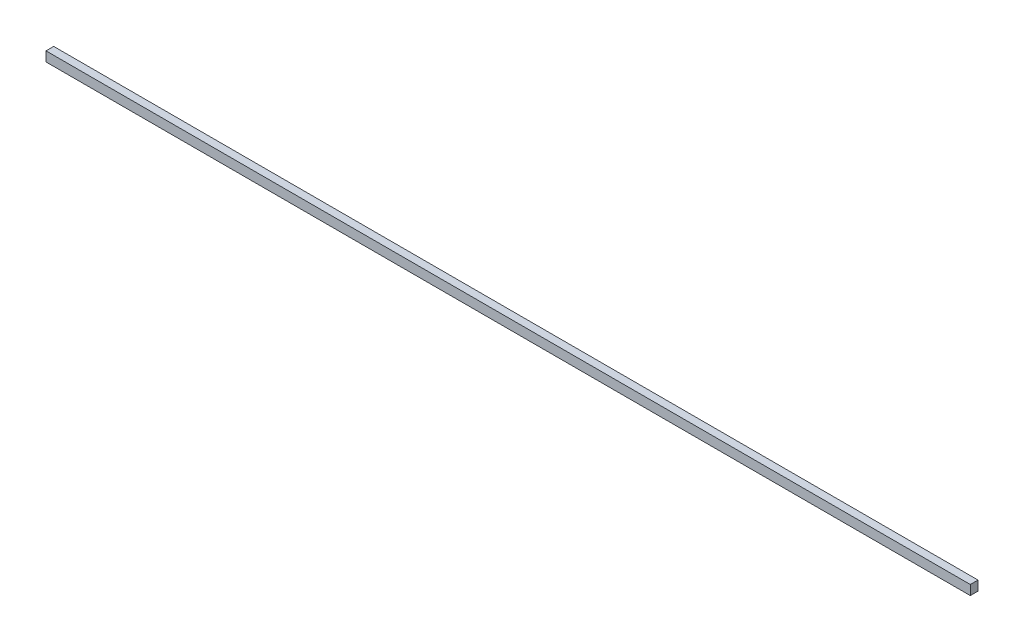
from build123d import *

# Parameters (mm, degrees)
SKETCH1_W           = 609.6
SKETCH1_H           = 6.35
BOSS_EXTRUDE1_DEPTH = 2.54


with BuildPart() as part:
    # Sketch1 → Boss-Extrude1 (new body, symmetric)
    with BuildSketch(Plane.XY):
        Rectangle(SKETCH1_W, SKETCH1_H)
    extrude(amount=BOSS_EXTRUDE1_DEPTH, both=True)


solid = part.part
